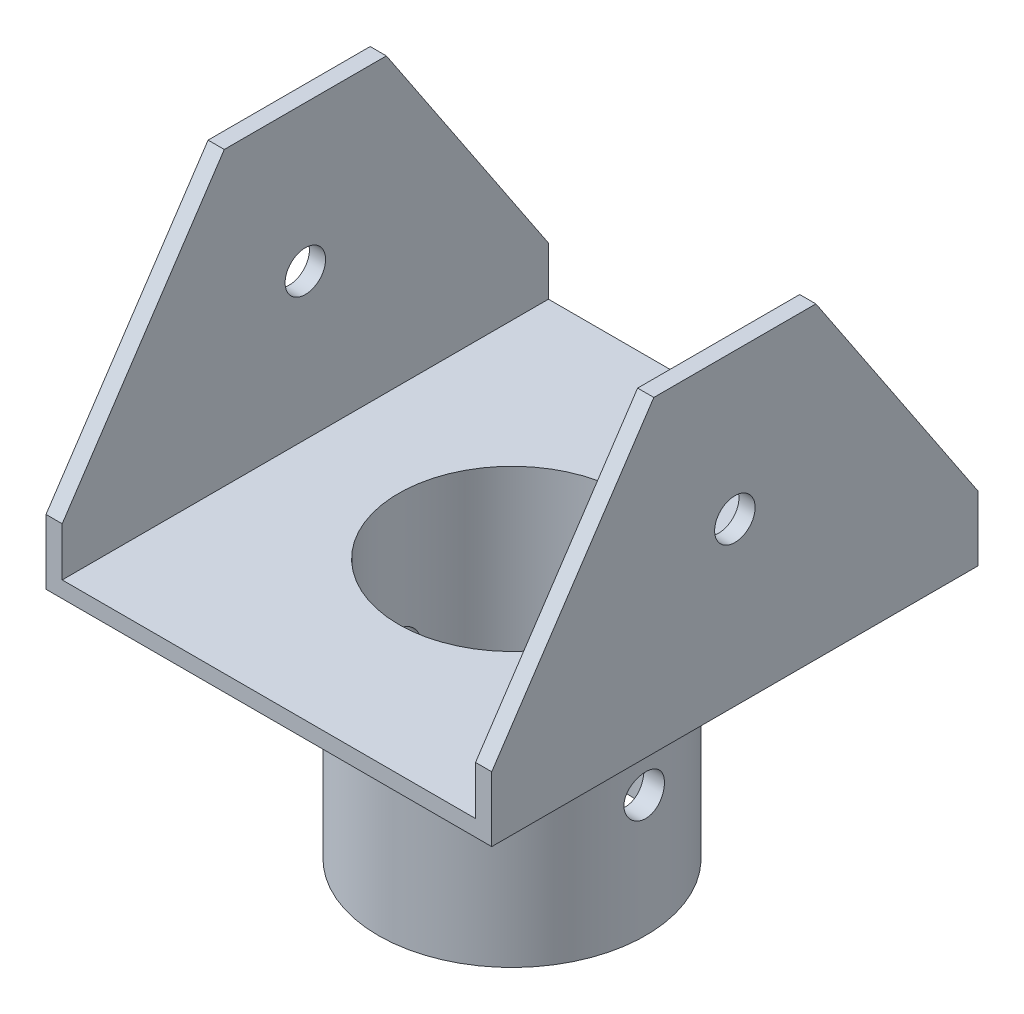
from build123d import *

# Parameters (mm, degrees)
SKETCH_1_R           = 16.5
SKETCH_1_R_2         = 14
EXTRUDE_1_DEPTH      = 30
EXTRUDE_2_DEPTH      = 30
EXTRUDE_2_DEPTH_BACK = 30
SKETCH_3_R           = 14
CUT_EXTRUDE_1_DEPTH  = 50
SKETCH_4_R           = 2.5
CUT_EXTRUDE_2_DEPTH  = 93.460802506


with BuildPart() as part:
    # 草图1 → 凸台-拉伸1 (new body)
    with BuildSketch(Plane(origin=(0, 0, 0), x_dir=(1, 0, 0), z_dir=(0, 1, 0))):
        Circle(SKETCH_1_R)
        Circle(SKETCH_1_R_2, mode=Mode.SUBTRACT)
    extrude(amount=EXTRUDE_1_DEPTH)

    # 草图2 → 凸台-拉伸2 (add, two sides: drawn at the far end of the back side and taken through both)
    with BuildSketch(Plane.XY.offset(-EXTRUDE_2_DEPTH_BACK)):
        Polygon((27.5, 30), (-27.5, 30), (-27.5, 68), (-25.5, 68), (-25.5, 32), (25.5, 32), (25.5, 68), (27.5, 68), align=None)
    extrude(amount=EXTRUDE_2_DEPTH + EXTRUDE_2_DEPTH_BACK)

    # 草图3 → 切除-拉伸1 (cut)
    with BuildSketch(Plane.XZ.offset(-30)):
        Circle(SKETCH_3_R)
    extrude(amount=-CUT_EXTRUDE_1_DEPTH, mode=Mode.SUBTRACT)

    # 草图4 → 切除-拉伸2 (cut, through all)
    with BuildSketch(Plane(origin=(27.5, 0, 0), x_dir=(0, 0, -1), z_dir=(1, 0, 0))):
        with Locations((0, 50)):
            Circle(SKETCH_4_R)
        with Locations((0, 15)):
            Circle(SKETCH_4_R)
        Polygon((-30, 38), (-30, 68), (-10, 68), align=None)
        Polygon((30, 68), (10, 68), (30, 38), align=None)
    extrude(amount=-CUT_EXTRUDE_2_DEPTH, mode=Mode.SUBTRACT)


solid = part.part
